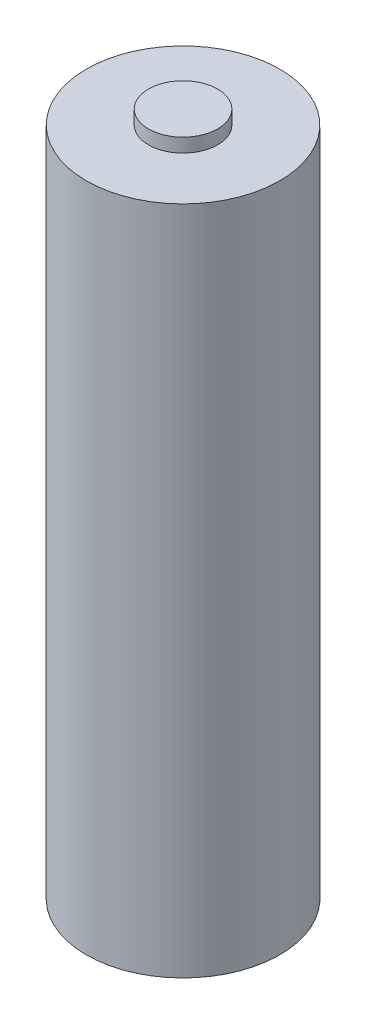
from build123d import *

# Parameters (mm, degrees)
SKETCH1_R           = 7
BOSS_EXTRUDE1_DEPTH = 48.5
SKETCH2_R           = 2.5
BOSS_EXTRUDE2_DEPTH = 1
SKETCH3_R           = 3.5
CUT_EXTRUDE1_DEPTH  = 0.01


with BuildPart() as part:
    # Sketch1 → Boss-Extrude1 (new body)
    with BuildSketch(Plane(origin=(0, 0, 0), x_dir=(1, 0, 0), z_dir=(0, 1, 0))):
        Circle(SKETCH1_R)
    extrude(amount=BOSS_EXTRUDE1_DEPTH)

    # Sketch2 → Boss-Extrude2 (add)
    with BuildSketch(Plane(origin=(0, 48.5, 0), x_dir=(1, 0, 0), z_dir=(0, 1, 0))):
        Circle(SKETCH2_R)
    extrude(amount=BOSS_EXTRUDE2_DEPTH)

    # Sketch3 → Cut-Extrude1 (cut)
    with BuildSketch(Plane(origin=(0, 0, 0), x_dir=(-1, 0, 0), z_dir=(0, -1, 0))):
        Circle(SKETCH3_R)
    extrude(amount=-CUT_EXTRUDE1_DEPTH, mode=Mode.SUBTRACT)


solid = part.part
